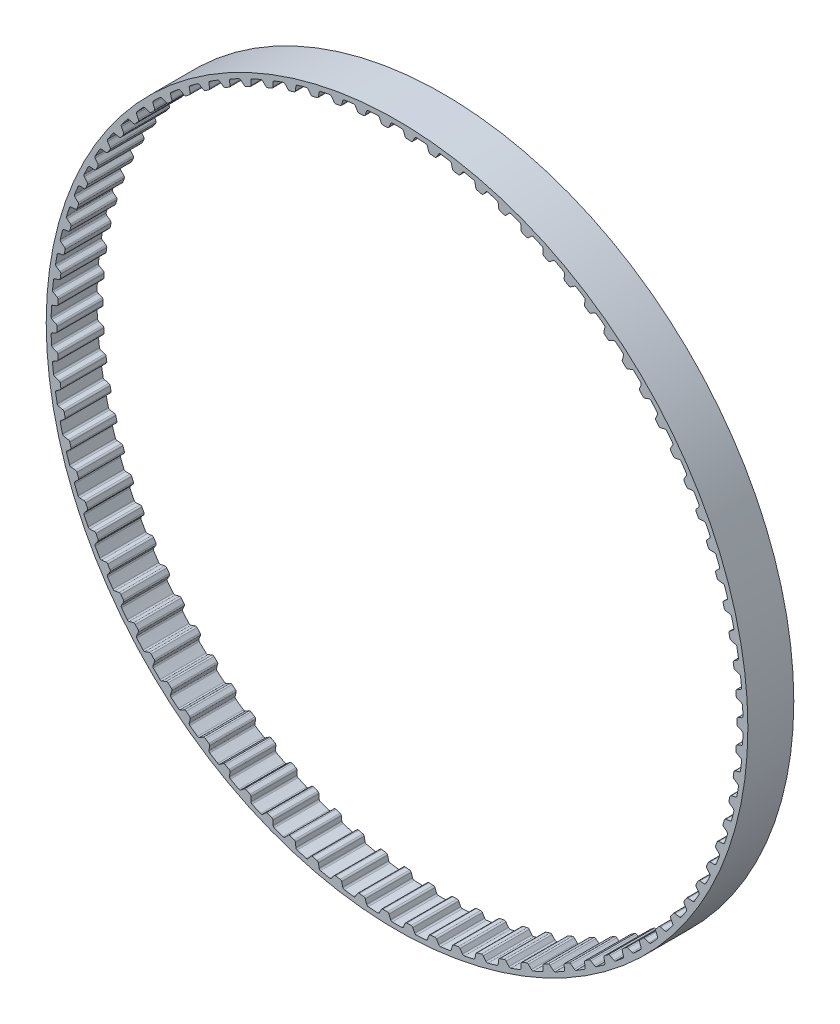
from build123d import *

# Parameters (mm, degrees)
SKETCH1_R           = 72.765701444
SKETCH1_R_2         = 70.479701444
BOSS_EXTRUDE1_DEPTH = 4.7625
CUT_EXTRUDE1_DEPTH  = 4.7625
CIRPATTERN1_COUNT   = 90


with BuildPart() as part:
    # Sketch1 → Boss-Extrude1 (new body, symmetric)
    with BuildSketch(Plane.XY):
        Circle(SKETCH1_R)
        Circle(SKETCH1_R_2, mode=Mode.SUBTRACT)
    extrude(amount=BOSS_EXTRUDE1_DEPTH, both=True)

    # Sketch3 → Cut-Extrude1 (cut, symmetric)
    with BuildSketch(Plane.XY):
        with BuildLine():
            Line((-2.009142305, 70.451058635), (2.009142305, 70.451058635))
            ThreePointArc((2.009142305, 70.451058635), (1.80520783, 70.517223191), (1.669291001, 70.683035238))
            Line((1.669291001, 70.683035238), (1.317833618, 71.511016946))
            ThreePointArc((1.317833618, 71.511016946), (1.179557139, 71.678426746), (0.972284221, 71.743113403))
            ThreePointArc((0.972284221, 71.743113403), (0, 71.749701444), (-0.972284221, 71.743113403))
            ThreePointArc((-0.972284221, 71.743113403), (-1.179557139, 71.678426746), (-1.317833618, 71.511016946))
            Line((-1.317833618, 71.511016946), (-1.669291001, 70.683035238))
            ThreePointArc((-1.669291001, 70.683035238), (-1.80520783, 70.517223191), (-2.009142305, 70.451058635))
        make_face()
    cut_extrude1 = extrude(amount=CUT_EXTRUDE1_DEPTH, both=True, mode=Mode.SUBTRACT)

    # CirPattern1: Cut-Extrude1 ×90 about axis
    cirpattern1_axis = Axis((0, 0, 0), (0, 0, 1))
    for i in range(1, CIRPATTERN1_COUNT):
        add(cut_extrude1.rotate(cirpattern1_axis, i * 360 / CIRPATTERN1_COUNT), mode=Mode.SUBTRACT)


solid = part.part
